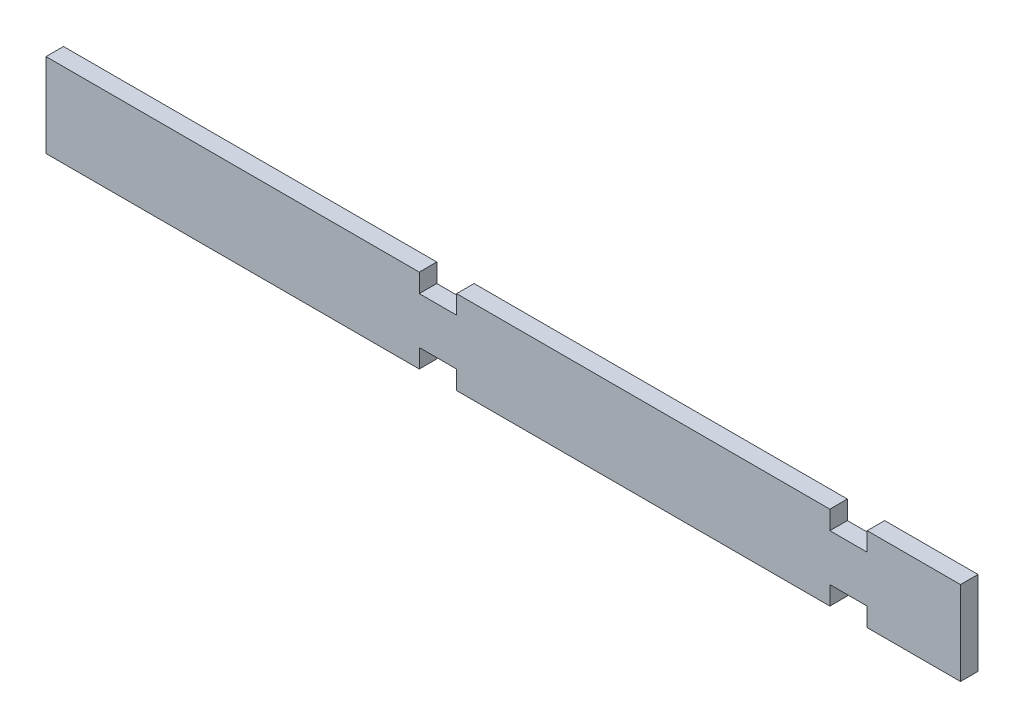
from build123d import *

# Parameters (mm, degrees)
BOSS_EXTRUDE1_DEPTH = 1.190625


with BuildPart() as part:
    # Sketch2 → Boss-Extrude1 (new body, symmetric)
    with BuildSketch(Plane.XY):
        Polygon((-62.23, 5.715), (-62.23, -5.715), (-11.43, -5.715), (-11.43, -3.175), (-6.35, -3.175), (-6.35, -5.715), (44.45, -5.715), (44.45, -3.175), (49.53, -3.175), (49.53, -5.715), (62.23, -5.715), (62.23, 5.715), (49.53, 5.715), (49.53, 3.175), (44.45, 3.175), (44.45, 5.715), (-6.35, 5.715), (-6.35, 3.175), (-11.43, 3.175), (-11.43, 5.715), align=None)
    extrude(amount=BOSS_EXTRUDE1_DEPTH, both=True)


solid = part.part
